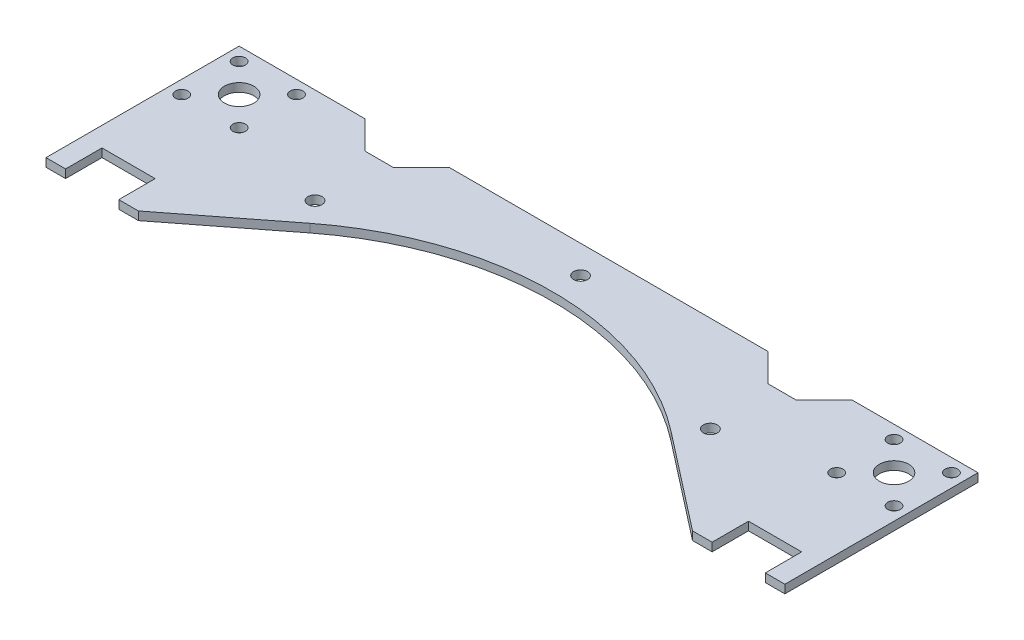
from build123d import *

# Parameters (mm, degrees)
ESQUISSE1_R      = 5.25
ESQUISSE1_R_2    = 2.25
ESQUISSE1_R_3    = 2.5
EXTRUSION1_DEPTH = 3


with BuildPart() as part:
    # Esquisse1 → Extrusion1 (new body)
    with BuildSketch(Plane(origin=(0, 0, 0), x_dir=(1, 0, 0), z_dir=(0, 1, 0))):
        with BuildLine():
            Line((-64.494367887, 52.858171056), (-99, 26))
            Line((-99, 26), (-106, 26))
            Line((-106, 26), (-106, 39))
            Line((-106, 39), (-125, 39))
            Line((-125, 39), (-125, 26))
            Line((-125, 26), (-132, 26))
            Line((-132, 26), (-132, 95))
            Line((-132, 95), (-87, 95))
            Line((-87, 95), (-77, 85))
            Line((-77, 85), (-67, 85))
            Line((-67, 85), (-57, 95))
            Line((-57, 95), (57, 95))
            Line((57, 95), (67, 85))
            Line((67, 85), (77, 85))
            Line((77, 85), (87, 95))
            Line((87, 95), (132, 95))
            Line((132, 95), (132, 26))
            Line((132, 26), (125, 26))
            Line((125, 26), (125, 39))
            Line((125, 39), (106, 39))
            Line((106, 39), (106, 26))
            Line((106, 26), (99, 26))
            Line((99, 26), (64.494367887, 52.858171056))
            ThreePointArc((64.494367887, 52.858171056), (0, 75), (-64.494367887, 52.858171056))
        make_face()
        with Locations((-117, 80)):
            Circle(ESQUISSE1_R, mode=Mode.SUBTRACT)
        with Locations((117, 80)):
            Circle(ESQUISSE1_R, mode=Mode.SUBTRACT)
        with Locations((-127.253048327, 90.253048327)):
            Circle(ESQUISSE1_R_2, mode=Mode.SUBTRACT)
        with Locations((-106.746951673, 90.253048327)):
            Circle(ESQUISSE1_R_2, mode=Mode.SUBTRACT)
        with Locations((-106.746951673, 69.746951673)):
            Circle(ESQUISSE1_R_2, mode=Mode.SUBTRACT)
        with Locations((-127.253048327, 69.746951673)):
            Circle(ESQUISSE1_R_2, mode=Mode.SUBTRACT)
        with Locations((106.746951673, 69.746951673)):
            Circle(ESQUISSE1_R_2, mode=Mode.SUBTRACT)
        with Locations((127.253048327, 69.746951673)):
            Circle(ESQUISSE1_R_2, mode=Mode.SUBTRACT)
        with Locations((127.253048327, 90.253048327)):
            Circle(ESQUISSE1_R_2, mode=Mode.SUBTRACT)
        with Locations((106.746951673, 90.253048327)):
            Circle(ESQUISSE1_R_2, mode=Mode.SUBTRACT)
        with Locations((-70.636688638, 60.749425443)):
            Circle(ESQUISSE1_R_3, mode=Mode.SUBTRACT)
        with Locations((70.636688638, 60.749425443)):
            Circle(ESQUISSE1_R_3, mode=Mode.SUBTRACT)
        with Locations((0, 85)):
            Circle(ESQUISSE1_R_3, mode=Mode.SUBTRACT)
    extrude(amount=EXTRUSION1_DEPTH)


solid = part.part
